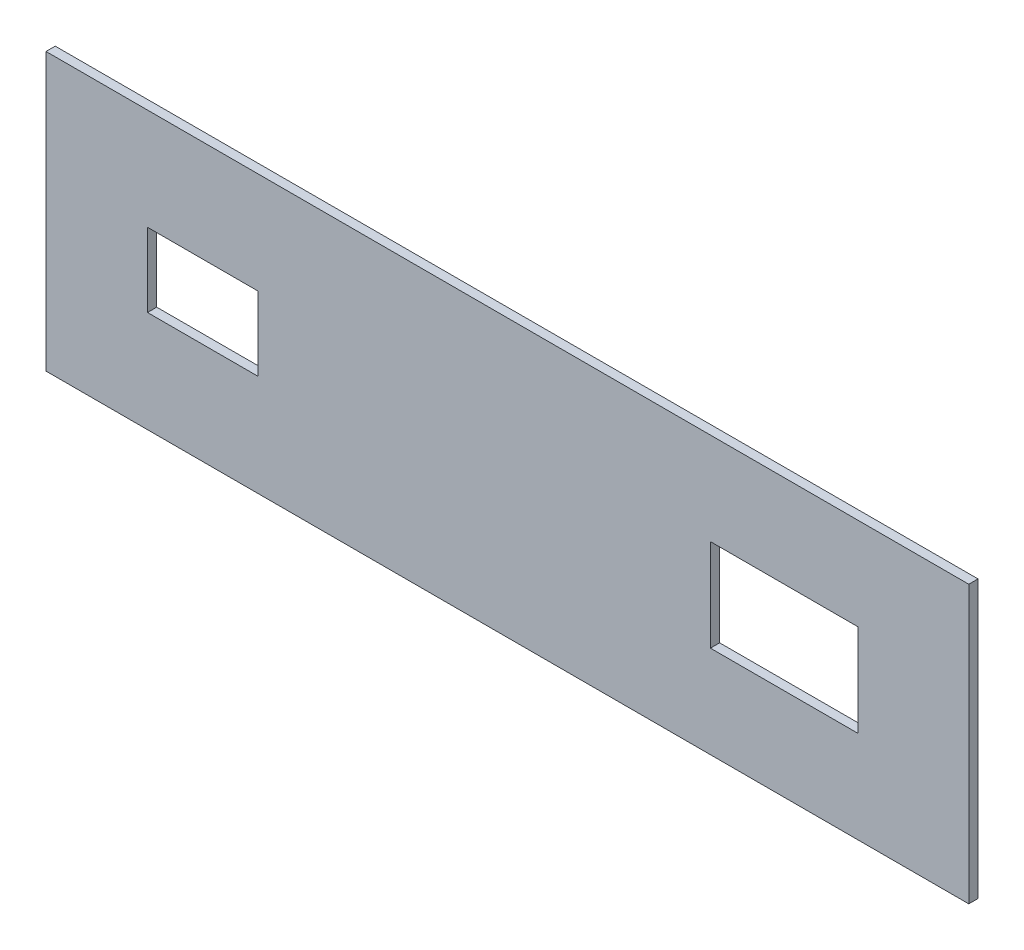
from build123d import *

# Parameters (mm, degrees)
SKETCH1_W           = 500
SKETCH1_H           = 150
SKETCH1_W_2         = 60
SKETCH1_H_2         = 40
SKETCH1_W_3         = 80
SKETCH1_H_3         = 50
BOSS_EXTRUDE1_DEPTH = 5


with BuildPart() as part:
    # Sketch1 → Boss-Extrude1 (new body)
    with BuildSketch(Plane.XY):
        Rectangle(SKETCH1_W, SKETCH1_H)
        with Locations((-165, 0)):
            Rectangle(SKETCH1_W_2, SKETCH1_H_2, mode=Mode.SUBTRACT)
        with Locations((150, 0)):
            Rectangle(SKETCH1_W_3, SKETCH1_H_3, mode=Mode.SUBTRACT)
    extrude(amount=BOSS_EXTRUDE1_DEPTH)


solid = part.part
